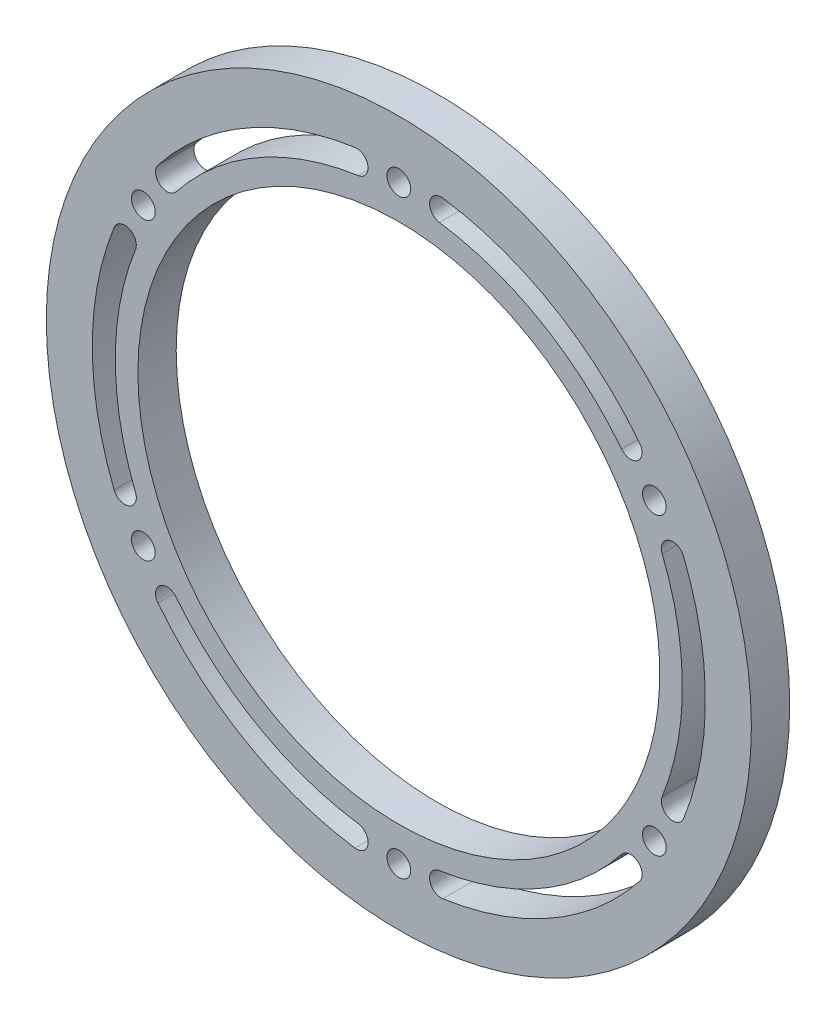
from build123d import *

# Parameters (mm, degrees)
SKETCH_1_R      = 46
SKETCH_1_R_2    = 1.55
SKETCH_1_R_3    = 34.05
EXTRUDE_1_DEPTH = 5


with BuildPart() as part:
    # 草图1 → 凸台-拉伸1 (new body)
    with BuildSketch(Plane.XY.offset(2.5)):
        Circle(SKETCH_1_R)
        with Locations((33.341978046, 19.25)):
            Circle(SKETCH_1_R_2, mode=Mode.SUBTRACT)
        with Locations((33.341978046, -19.25)):
            Circle(SKETCH_1_R_2, mode=Mode.SUBTRACT)
        with Locations((0, -38.5)):
            Circle(SKETCH_1_R_2, mode=Mode.SUBTRACT)
        with Locations((-33.341978046, -19.25)):
            Circle(SKETCH_1_R_2, mode=Mode.SUBTRACT)
        with Locations((-33.341978046, 19.25)):
            Circle(SKETCH_1_R_2, mode=Mode.SUBTRACT)
        with Locations((0, 38.5)):
            Circle(SKETCH_1_R_2, mode=Mode.SUBTRACT)
        Circle(SKETCH_1_R_3, mode=Mode.SUBTRACT)
        with BuildLine():
            ThreePointArc((-5.298278059, 36.618687164), (-18.5, 32.04293994), (-29.063574308, 22.897786978))
            ThreePointArc((-29.063574308, 22.897786978), (-31.170115981, 22.647822626), (-31.420080332, 24.7543643))
            ThreePointArc((-31.420080332, 24.7543643), (-20, 34.641016151), (-5.727868172, 39.587769907))
            ThreePointArc((-5.727868172, 39.587769907), (-4.028531744, 38.318023592), (-5.298278059, 36.618687164))
        make_face(mode=Mode.SUBTRACT)
        with BuildLine():
            ThreePointArc((29.063574308, 22.897786978), (18.5, 32.04293994), (5.298278059, 36.618687164))
            ThreePointArc((5.298278059, 36.618687164), (4.028531744, 38.318023592), (5.727868172, 39.587769907))
            ThreePointArc((5.727868172, 39.587769907), (20, 34.641016151), (31.420080332, 24.7543643))
            ThreePointArc((31.420080332, 24.7543643), (31.170115981, 22.647822626), (29.063574308, 22.897786978))
        make_face(mode=Mode.SUBTRACT)
        with BuildLine():
            ThreePointArc((34.361852367, -13.720900186), (37, 0), (34.361852367, 13.720900186))
            ThreePointArc((34.361852367, 13.720900186), (35.198647725, 15.670200965), (37.147948505, 14.833405607))
            ThreePointArc((37.147948505, 14.833405607), (40, 0), (37.147948505, -14.833405607))
            ThreePointArc((37.147948505, -14.833405607), (35.198647725, -15.670200965), (34.361852367, -13.720900186))
        make_face(mode=Mode.SUBTRACT)
        with BuildLine():
            ThreePointArc((5.298278059, -36.618687164), (18.5, -32.04293994), (29.063574308, -22.897786978))
            ThreePointArc((29.063574308, -22.897786978), (31.170115981, -22.647822626), (31.420080332, -24.7543643))
            ThreePointArc((31.420080332, -24.7543643), (20, -34.641016151), (5.727868172, -39.587769907))
            ThreePointArc((5.727868172, -39.587769907), (4.028531744, -38.318023592), (5.298278059, -36.618687164))
        make_face(mode=Mode.SUBTRACT)
        with BuildLine():
            ThreePointArc((-29.063574308, -22.897786978), (-18.5, -32.04293994), (-5.298278059, -36.618687164))
            ThreePointArc((-5.298278059, -36.618687164), (-4.028531744, -38.318023592), (-5.727868172, -39.587769907))
            ThreePointArc((-5.727868172, -39.587769907), (-20, -34.641016151), (-31.420080332, -24.7543643))
            ThreePointArc((-31.420080332, -24.7543643), (-31.170115981, -22.647822626), (-29.063574308, -22.897786978))
        make_face(mode=Mode.SUBTRACT)
        with BuildLine():
            ThreePointArc((-34.361852367, 13.720900186), (-37, 0), (-34.361852367, -13.720900186))
            ThreePointArc((-34.361852367, -13.720900186), (-35.198647725, -15.670200965), (-37.147948505, -14.833405607))
            ThreePointArc((-37.147948505, -14.833405607), (-40, 0), (-37.147948505, 14.833405607))
            ThreePointArc((-37.147948505, 14.833405607), (-35.198647725, 15.670200965), (-34.361852367, 13.720900186))
        make_face(mode=Mode.SUBTRACT)
    extrude(amount=-EXTRUDE_1_DEPTH)


solid = part.part
